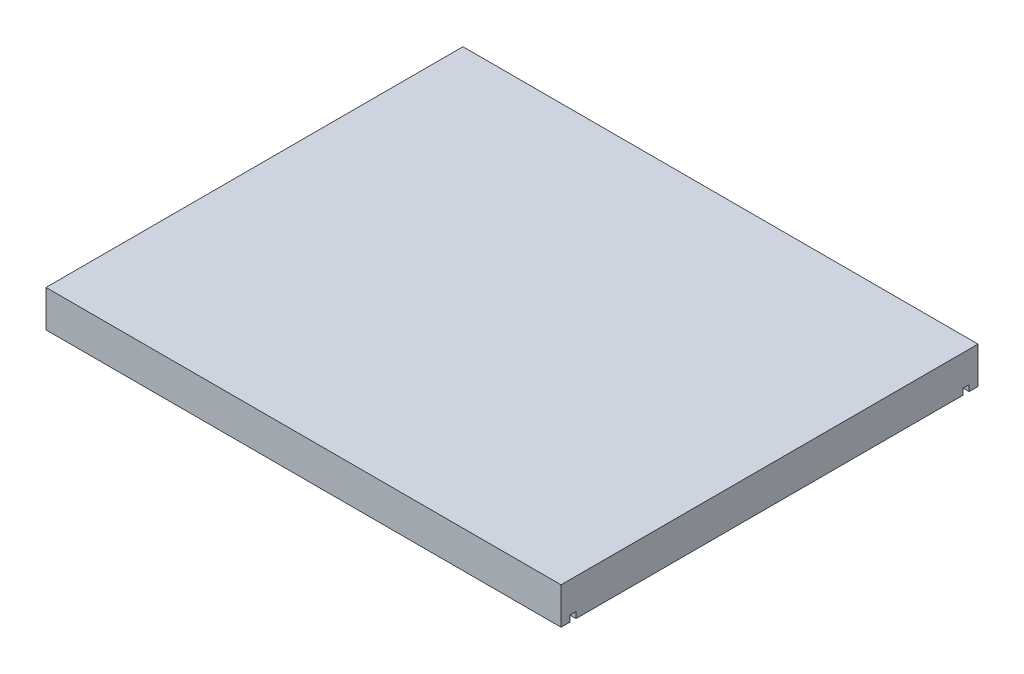
from build123d import *

# Parameters (mm, degrees)
SKETCH1_W           = 266.7
SKETCH1_H           = 215.9
BOSS_EXTRUDE1_DEPTH = 19.05
SKETCH3_W           = 3.175
SKETCH3_H           = 3.175
CUT_EXTRUDE2_DEPTH  = 134.35


with BuildPart() as part:
    # Sketch1 → Boss-Extrude1 (new body)
    with BuildSketch(Plane(origin=(0, 0, 0), x_dir=(1, 0, 0), z_dir=(0, 1, 0))):
        Rectangle(SKETCH1_W, SKETCH1_H)
    extrude(amount=BOSS_EXTRUDE1_DEPTH)

    # Sketch3 → Cut-Extrude2 (cut, symmetric)
    with BuildSketch(Plane(origin=(0, 0, 0), x_dir=(0, 0, -1), z_dir=(1, 0, 0))):
        with Locations((-101.7905, 1.5875)):
            Rectangle(SKETCH3_W, SKETCH3_H)
    cut_extrude2 = extrude(amount=CUT_EXTRUDE2_DEPTH, both=True, mode=Mode.SUBTRACT)

    # Mirror2: Cut-Extrude2 across plane
    add(cut_extrude2.mirror(Plane.XY), mode=Mode.SUBTRACT)


solid = part.part
